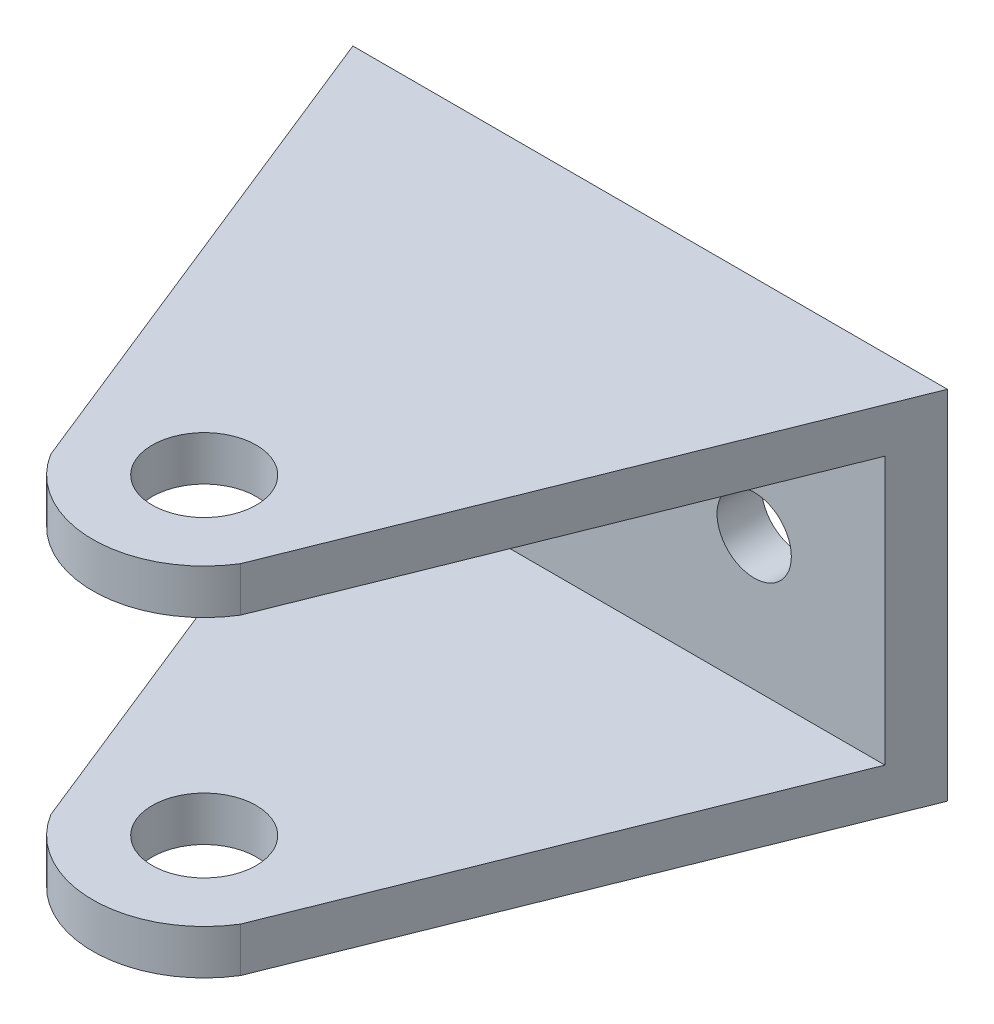
from build123d import *

# Parameters (mm, degrees)
SKETCH_1_R          = 2.5
EXTRUDE_1_DEPTH     = 3
SKETCH_2_W          = 40
SKETCH_2_H          = 3
EXTRUDE_2_DEPTH     = 40
SKETCH_3_R          = 3.5
CUT_EXTRUDE_1_DEPTH = 40


with BuildPart() as part:
    # 草图1 → 凸台-拉伸1 (new body)
    with BuildSketch(Plane.XY):
        Polygon((-29.772681171, 16.394648222), (-29.772681171, -7.605351778), (0.227318829, -7.605351778), (10.227318829, -7.605351778), (10.227318829, 16.394648222), align=None)
        with Locations((-19.772681171, 4.394648222)):
            Circle(SKETCH_1_R, mode=Mode.SUBTRACT)
        with Locations((0.227318829, 4.394648222)):
            Circle(SKETCH_1_R, mode=Mode.SUBTRACT)
    extrude(amount=EXTRUDE_1_DEPTH)

    # 草图2 → 凸台-拉伸2 (add)
    with BuildSketch(Plane.XY.offset(3)):
        with Locations((-9.772681171, -6.105351778)):
            Rectangle(SKETCH_2_W, SKETCH_2_H)
        with Locations((-9.772681171, 14.894648222)):
            Rectangle(SKETCH_2_W, SKETCH_2_H)
    extrude(amount=EXTRUDE_2_DEPTH)

    # 草图3 → 切除-拉伸1 (cut)
    with BuildSketch(Plane.XZ.offset(7.605351778)):
        with Locations((-9.772681171, 30)):
            Circle(SKETCH_3_R)
        with BuildLine():
            Line((-29.772681171, 0), (-66.242845542, 33.938537382))
            Line((-66.242845542, 33.938537382), (4.749976108, 60.991202945))
            Line((4.749976108, 60.991202945), (36.387923144, 40.281675758))
            Line((36.387923144, 40.281675758), (10.227318829, 0))
            Line((10.227318829, 0), (-3.390054495, 33.938537382))
            ThreePointArc((-3.390054495, 33.938537382), (-9.772681171, 37.5), (-16.155307848, 33.938537382))
            Line((-16.155307848, 33.938537382), (-29.772681171, 0))
        make_face()
    extrude(amount=-CUT_EXTRUDE_1_DEPTH, mode=Mode.SUBTRACT)


solid = part.part
